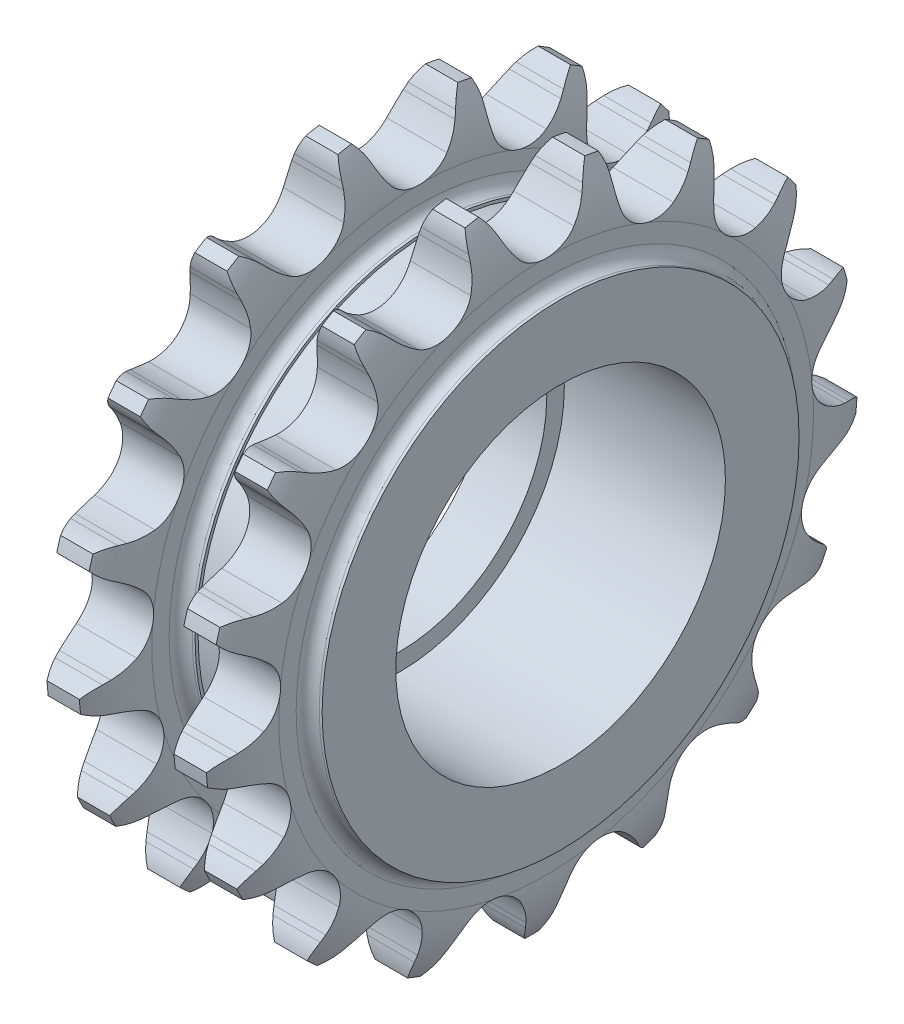
from build123d import *

# Parameters (mm, degrees)
EXTRUDECUTONE_DEPTH     = 6.429696134
PATTERNONE_COUNT        = 17
LPATTERNA_COUNT         = 2
LPATTERNA_PITCH         = 18.11
SKETCHPAI_R             = 33.565
BOSS_EXTRUDEA_DEPTH     = 18.11
CUT_EXTRUDEA_DEPTH      = 71.112148213
CUT_EXTRUDEA_DEPTH_BACK = 71.112148213
SKETCHHOLE_R            = 23.5
EXTRUDE_START           = -8
SKETCH_4_R              = 23.5
SKETCH_4_R_2            = 21
EXTRUDE_2_DEPTH         = 8


with BuildPart() as part:
    # Sketch1 → Revolve 2 (revolve)
    with BuildSketch(Plane.XY):
        with BuildLine():
            Line((-6.429696134, 0), (-6.429696134, 34))
            Line((-6.429696134, 34), (-6.017956907, 34))
            ThreePointArc((-6.017956907, 34), (-4.85338251, 34.48238251), (-4.371, 35.646956907))
            Line((-4.371, 35.646956907), (-4.371, 38.117392267))
            ThreePointArc((-4.371, 38.117392267), (-3.919878552, 42.451674331), (-2.30725, 46.5))
            Line((-2.30725, 46.5), (2.30725, 46.5))
            ThreePointArc((2.30725, 46.5), (3.919878552, 42.451674331), (4.371, 38.117392267))
            Line((4.371, 38.117392267), (4.371, 35.646956907))
            ThreePointArc((4.371, 35.646956907), (4.85338251, 34.48238251), (6.017956907, 34))
            Line((6.017956907, 34), (6.429696134, 34))
            Line((6.429696134, 34), (6.429696134, 0))
            Line((6.429696134, 0), (-6.429696134, 0))
        make_face()
    revolve(axis=Axis((-4, 0, 0), (1, 0, 0)))

    # Sketch2 → ExtrudeCutOne (cut, symmetric)
    with BuildSketch(Plane(origin=(0, 0, 0), x_dir=(0, 0, -1), z_dir=(1, 0, 0))):
        with BuildLine():
            Line((5.793131969, 42.895011616), (6.18114945, 43.773787436))
            ThreePointArc((6.18114945, 43.773787436), (6.790313357, 44.8857779), (7.579548398, 45.878104212))
            ThreePointArc((7.579548398, 45.878104212), (0, 46.5), (-7.579548398, 45.878104212))
            ThreePointArc((-7.579548398, 45.878104212), (-6.790313357, 44.8857779), (-6.18114945, 43.773787436))
            Line((-6.18114945, 43.773787436), (-5.793131969, 42.895011616))
            ThreePointArc((-5.793131969, 42.895011616), (-5.006529608, 41.38396254), (-4.033010117, 39.986009613))
            ThreePointArc((-4.033010117, 39.986009613), (0, 38.041992267), (4.033010117, 39.986009613))
            ThreePointArc((4.033010117, 39.986009613), (5.006529608, 41.38396254), (5.793131969, 42.895011616))
        make_face()
    extrudecutone = extrude(amount=EXTRUDECUTONE_DEPTH, both=True, mode=Mode.SUBTRACT)

    # PatternOne: ExtrudeCutOne ×17 about axis
    patternone_axis = Axis((-4, 0, 0), (1, 0, 0))
    for i in range(1, PATTERNONE_COUNT):
        add(extrudecutone.rotate(patternone_axis, i * 360 / PATTERNONE_COUNT), mode=Mode.SUBTRACT)


with BuildPart() as lpatterna_1:
    # LPatternA: pattern copy
    add(part.part.moved(Location(Vector(1, 0, 0) * (1 * LPATTERNA_PITCH))))


with BuildPart() as part_1:
    add(part.part)

    add(lpatterna_1.part)  # Boss-ExtrudeA merges LPatternA_1
    # SketchPai → Boss-ExtrudeA (add)
    with BuildSketch(Plane(origin=(0, 0, 0), x_dir=(0, 0, -1), z_dir=(1, 0, 0))):
        Circle(SKETCHPAI_R)
    extrude(amount=BOSS_EXTRUDEA_DEPTH)

    # SketchHole → Cut-ExtrudeA (cut, two sides: drawn at the far end of the back side and taken through both)
    with BuildSketch(Plane(origin=(0, 0, 0), x_dir=(0, 0, -1), z_dir=(1, 0, 0)).offset(-CUT_EXTRUDEA_DEPTH_BACK)):
        Circle(SKETCHHOLE_R)
    extrude(amount=CUT_EXTRUDEA_DEPTH + CUT_EXTRUDEA_DEPTH_BACK, mode=Mode.SUBTRACT)

    # 草图4 → 凸台-拉伸2 (add)
    with BuildSketch(Plane.ZY.offset(6.429696134).offset(EXTRUDE_START)):
        Circle(SKETCH_4_R)
        Circle(SKETCH_4_R_2, mode=Mode.SUBTRACT)
    extrude(amount=EXTRUDE_2_DEPTH)


solid = part_1.part
